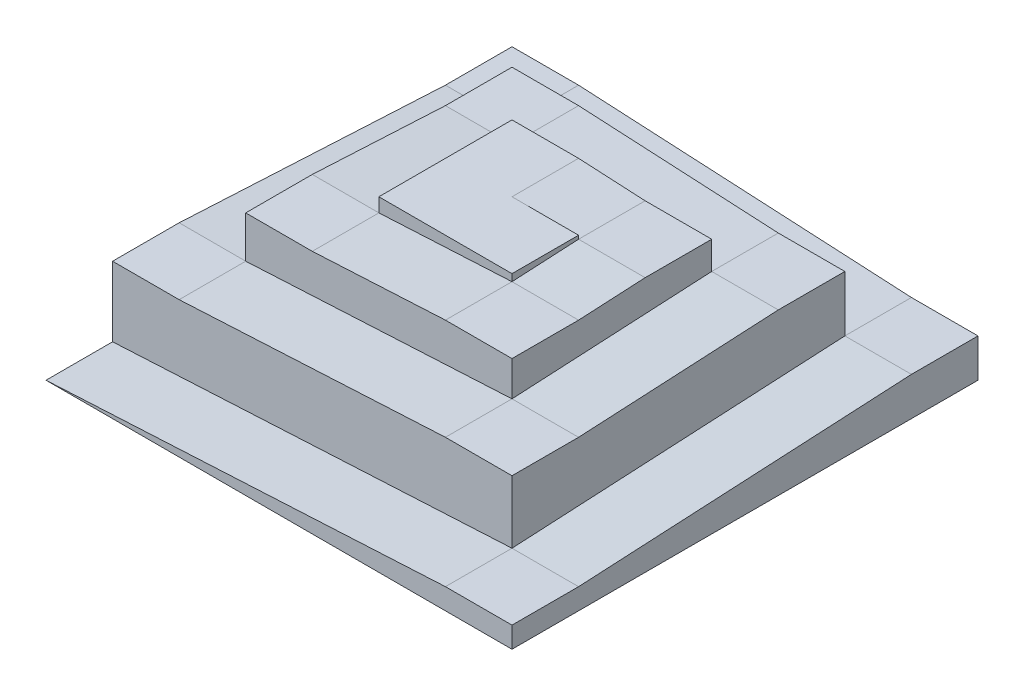
from build123d import *

# Parameters (mm, degrees)
BOSS_EXTRUDE1_DEPTH  = 19.05
BOSS_EXTRUDE2_DEPTH  = 19.05
BOSS_EXTRUDE3_DEPTH  = 19.05
BOSS_EXTRUDE4_DEPTH  = 19.05
BOSS_EXTRUDE5_DEPTH  = 19.05
BOSS_EXTRUDE6_DEPTH  = 19.05
BOSS_EXTRUDE7_DEPTH  = 19.05
BOSS_EXTRUDE8_DEPTH  = 19.05
BOSS_EXTRUDE9_DEPTH  = 19.05
BOSS_EXTRUDE10_DEPTH = 19.05
BOSS_EXTRUDE11_DEPTH = 19.05
SKETCH12_W           = 38.1
SKETCH12_H           = 35.941255032
BOSS_EXTRUDE12_DEPTH = 19.05


with BuildPart() as part:
    # Sketch1 → Boss-Extrude1 (new body)
    with BuildSketch(Plane.XY):
        Polygon((0, 0), (114.3, 5.990209172), (133.35, 5.990209172), (133.35, 0), align=None)
    extrude(amount=BOSS_EXTRUDE1_DEPTH)

    # Sketch2 → Boss-Extrude2 (add)
    with BuildSketch(Plane(origin=(133.35, 0, 0), x_dir=(0, 0, -1), z_dir=(1, 0, 0))):
        Polygon((0, 0), (0, 5.990209172), (95.25, 10.982050149), (114.3, 10.982050149), (114.3, 0), align=None)
    extrude(amount=-BOSS_EXTRUDE2_DEPTH)

    # Sketch3 → Boss-Extrude3 (add)
    with BuildSketch(Plane(origin=(0, 0, -114.3), x_dir=(-1, 0, 0), z_dir=(0, 0, -1))):
        Polygon((-114.3, 0), (-114.3, 10.982050149), (-19.05, 15.973891125), (0, 15.973891125), (0, 0), align=None)
    extrude(amount=-BOSS_EXTRUDE3_DEPTH)

    # Sketch4 → Boss-Extrude4 (add)
    with BuildSketch(Plane.ZY):
        Polygon((-95.25, 15.973891125), (-19.05, 19.967363907), (0, 19.967363907), (0, 0), (-95.25, 0), align=None)
    extrude(amount=-BOSS_EXTRUDE4_DEPTH)

    # Sketch5 → Boss-Extrude5 (add)
    with BuildSketch(Plane.XY):
        Polygon((95.25, 23.960836688), (19.05, 19.967363907), (19.05, 0), (114.3, 0), (114.3, 23.960836688), align=None)
    extrude(amount=-BOSS_EXTRUDE5_DEPTH)

    # Sketch6 → Boss-Extrude6 (add)
    with BuildSketch(Plane(origin=(114.3, 0, 0), x_dir=(0, 0, -1), z_dir=(1, 0, 0))):
        Polygon((19.05, 23.960836688), (76.2, 26.955941274), (95.25, 26.955941274), (95.25, 0), (19.05, 0), align=None)
    extrude(amount=-BOSS_EXTRUDE6_DEPTH)

    # Sketch7 → Boss-Extrude7 (add)
    with BuildSketch(Plane(origin=(0, 0, -95.25), x_dir=(-1, 0, 0), z_dir=(0, 0, -1))):
        Polygon((-95.25, 26.955941274), (-38.1, 29.95104586), (-19.05, 29.95104586), (-19.05, 0), (-95.25, 0), align=None)
    extrude(amount=-BOSS_EXTRUDE7_DEPTH)

    # Sketch8 → Boss-Extrude8 (add)
    with BuildSketch(Plane.ZY.offset(-19.05)):
        Polygon((-76.2, 29.95104586), (-38.1, 31.947782251), (-19.05, 31.947782251), (-19.05, 0), (-76.2, 0), align=None)
    extrude(amount=-BOSS_EXTRUDE8_DEPTH)

    # Sketch9 → Boss-Extrude9 (add)
    with BuildSketch(Plane.XY.offset(-19.05)):
        Polygon((38.1, 31.947782251), (76.2, 33.944518642), (95.25, 33.944518642), (95.25, 0), (38.1, 0), align=None)
    extrude(amount=-BOSS_EXTRUDE9_DEPTH)

    # Sketch10 → Boss-Extrude10 (add)
    with BuildSketch(Plane(origin=(95.25, 0, 0), x_dir=(0, 0, -1), z_dir=(1, 0, 0))):
        Polygon((38.1, 0), (38.1, 33.944518642), (57.15, 34.942886837), (76.2, 34.942886837), (76.2, 0), align=None)
    extrude(amount=-BOSS_EXTRUDE10_DEPTH)

    # Sketch11 → Boss-Extrude11 (add)
    with BuildSketch(Plane(origin=(0, 0, -76.2), x_dir=(-1, 0, 0), z_dir=(0, 0, -1))):
        Polygon((-76.2, 34.942886837), (-57.15, 35.941255032), (-38.1, 35.941255032), (-38.1, 0), (-76.2, 0), align=None)
    extrude(amount=-BOSS_EXTRUDE11_DEPTH)

    # Sketch12 → Boss-Extrude12 (add)
    with BuildSketch(Plane.XY.offset(-57.15)):
        with Locations((57.15, 17.970627516)):
            Rectangle(SKETCH12_W, SKETCH12_H)
    extrude(amount=BOSS_EXTRUDE12_DEPTH)


solid = part.part
